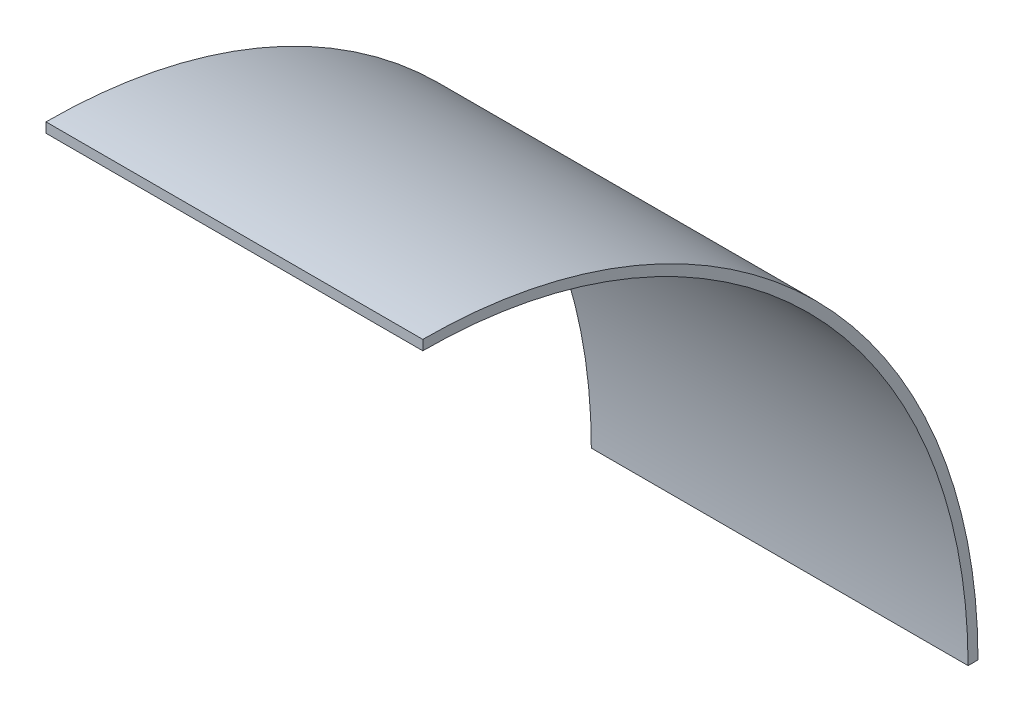
from build123d import *

# Parameters (mm, degrees)
BOSS_EXTRUDE1_DEPTH = 120.65


with BuildPart() as part:
    # Sketch1 → Boss-Extrude1 (new body)
    with BuildSketch(Plane(origin=(0, 0, 0), x_dir=(0, 0, -1), z_dir=(1, 0, 0))):
        with BuildLine():
            Line((0, 174.625), (0, 177.8))
            ThreePointArc((0, 177.8), (125.723585695, 125.723585695), (177.8, 0))
            Line((177.8, 0), (174.625, 0))
            ThreePointArc((174.625, 0), (123.478521665, 123.478521665), (0, 174.625))
        make_face()
    extrude(amount=BOSS_EXTRUDE1_DEPTH)


solid = part.part
